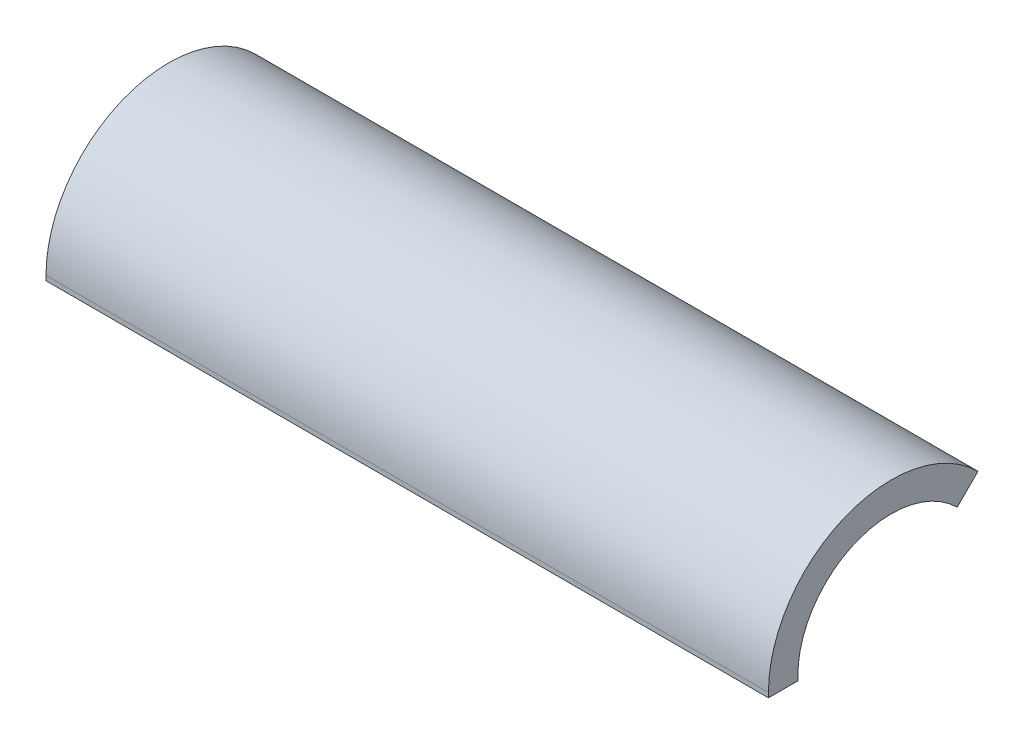
from build123d import *

# Parameters (mm, degrees)
BOSS_EXTRUDE1_DEPTH = 98.298
SKETCH2_W           = 98.298
SKETCH2_H           = 4.0005
BOSS_EXTRUDE2_DEPTH = 0.635


with BuildPart() as part:
    # Sketch1 → Boss-Extrude1 (new body)
    with BuildSketch(Plane(origin=(0, 0, 0), x_dir=(0, 0, -1), z_dir=(1, 0, 0))):
        with BuildLine():
            Line((-16.7005, 0), (-12.7, 0))
            ThreePointArc((-12.7, 0), (-4.860079591, 11.733270063), (8.980256121, 8.980256121))
            Line((8.980256121, 8.980256121), (11.809036799, 11.809036799))
            ThreePointArc((11.809036799, 11.809036799), (-6.391004662, 15.429250133), (-16.7005, 0))
        make_face()
    extrude(amount=BOSS_EXTRUDE1_DEPTH)

    # Sketch2 → Boss-Extrude2 (add)
    with BuildSketch(Plane.XZ):
        with Locations((49.149, 14.70025)):
            Rectangle(SKETCH2_W, SKETCH2_H)
    extrude(amount=BOSS_EXTRUDE2_DEPTH)


solid = part.part
